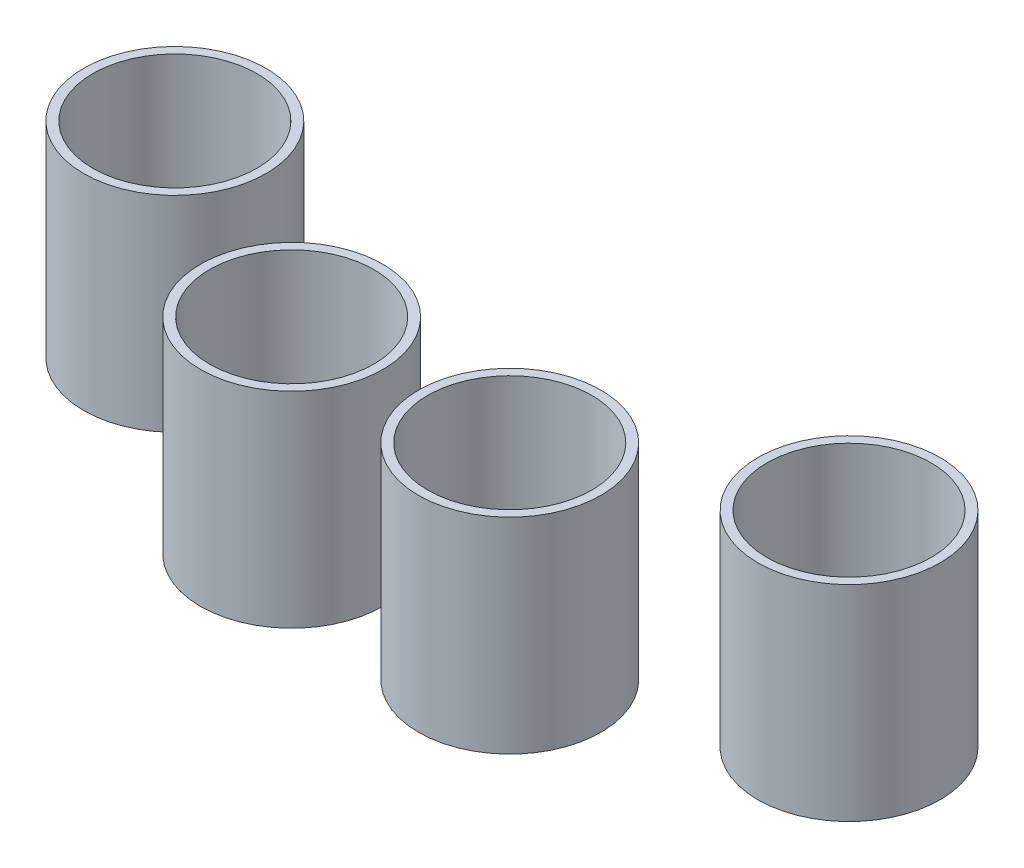
from build123d import *

# Parameters (mm, degrees)
SKETCH1_R             = 40
BOSS_EXTRUDE2_DEPTH   = 90
BOSS_EXTRUDE2_2_DEPTH = 90
BOSS_EXTRUDE2_3_DEPTH = 90
BOSS_EXTRUDE2_4_DEPTH = 90
SKETCH2_R             = 36
CUT_EXTRUDE1_DEPTH    = 80


with BuildPart() as part:
    # Sketch1 → Boss-Extrude2 (new body)
    with BuildSketch(Plane(origin=(0, 0, 0), x_dir=(1, 0, 0), z_dir=(0, 1, 0))):
        with Locations((-147.841150228, -176.190221917)):
            Circle(SKETCH1_R)
    extrude(amount=BOSS_EXTRUDE2_DEPTH)


with BuildPart() as body_2:
    # Sketch1 → Boss-Extrude2 2 (new body)
    with BuildSketch(Plane(origin=(0, 0, 0), x_dir=(1, 0, 0), z_dir=(0, 1, 0))):
        with Locations((-47.819688888, -224.973948169)):
            Circle(SKETCH1_R)
    extrude(amount=BOSS_EXTRUDE2_2_DEPTH)


with BuildPart() as body_3:
    # Sketch1 → Boss-Extrude2 3 (new body)
    with BuildSketch(Plane(origin=(0, 0, 0), x_dir=(1, 0, 0), z_dir=(0, 1, 0))):
        with Locations((47.819688888, -224.973948169)):
            Circle(SKETCH1_R)
    extrude(amount=BOSS_EXTRUDE2_3_DEPTH)


with BuildPart() as body_4:
    # Sketch1 → Boss-Extrude2 4 (new body)
    with BuildSketch(Plane(origin=(0, 0, 0), x_dir=(1, 0, 0), z_dir=(0, 1, 0))):
        with Locations((147.841150228, -176.190221917)):
            Circle(SKETCH1_R)
    extrude(amount=BOSS_EXTRUDE2_4_DEPTH)


with BuildPart() as cut_extrude1_tool:
    # Sketch2 → Cut-Extrude1 (new body)
    with BuildSketch(Plane(origin=(0, 90, 0), x_dir=(1, 0, 0), z_dir=(0, 1, 0))):
        with Locations((-47.819688888, -224.973948169)):
            Circle(SKETCH2_R)
        with Locations((-147.841150228, -176.190221917)):
            Circle(SKETCH2_R)
        with Locations((47.819688888, -224.973948169)):
            Circle(SKETCH2_R)
        with Locations((147.841150228, -176.190221917)):
            Circle(SKETCH2_R)
    extrude(amount=-CUT_EXTRUDE1_DEPTH)


with BuildPart() as part_1:
    add(part.part)

    # Cut-Extrude1: cut by cut_extrude1_tool
    add(cut_extrude1_tool.part, mode=Mode.SUBTRACT)


with BuildPart() as body_2_1:
    add(body_2.part)

    # Cut-Extrude1: cut by cut_extrude1_tool
    add(cut_extrude1_tool.part, mode=Mode.SUBTRACT)


with BuildPart() as body_3_1:
    add(body_3.part)

    # Cut-Extrude1: cut by cut_extrude1_tool
    add(cut_extrude1_tool.part, mode=Mode.SUBTRACT)


with BuildPart() as body_4_1:
    add(body_4.part)

    # Cut-Extrude1: cut by cut_extrude1_tool
    add(cut_extrude1_tool.part, mode=Mode.SUBTRACT)


solid = Compound([part_1.part, body_2_1.part, body_3_1.part, body_4_1.part])
